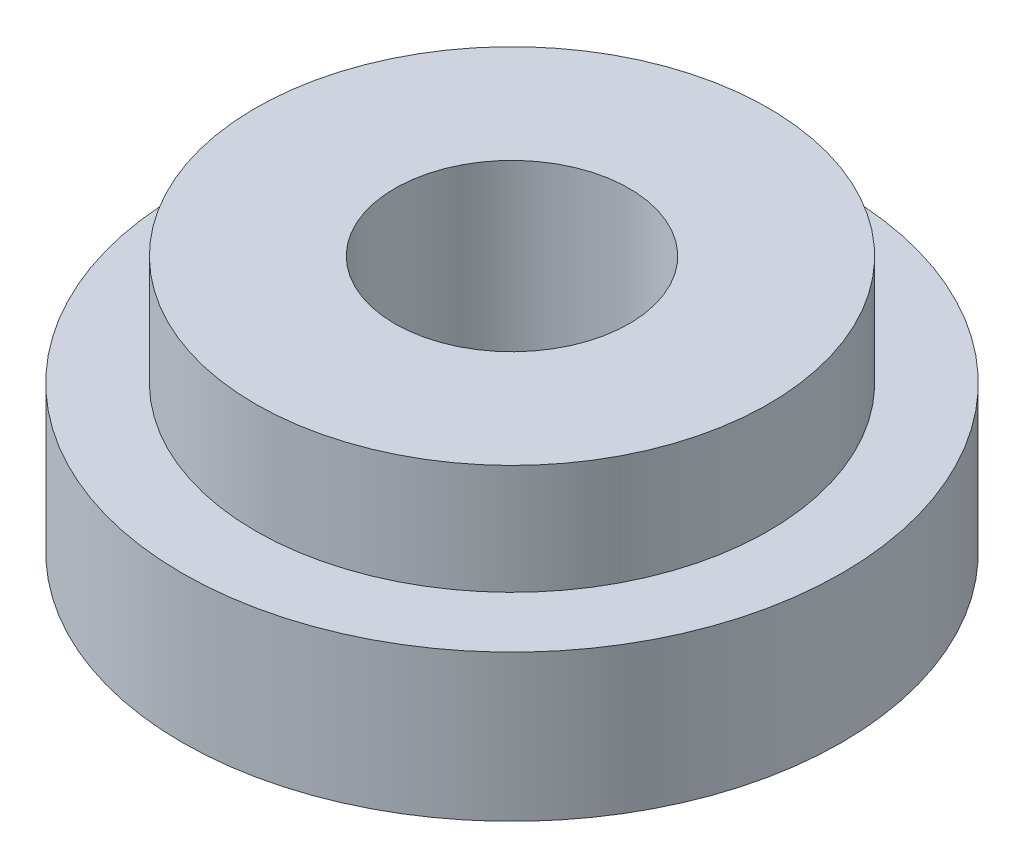
from build123d import *

# Parameters (mm, degrees)
SKETCH1_R           = 4.5
BOSS_EXTRUDE1_DEPTH = 2
SKETCH2_R           = 3.5
BOSS_EXTRUDE2_DEPTH = 1.5
SKETCH3_R           = 1.6
CUT_EXTRUDE1_DEPTH  = 4.5


with BuildPart() as part:
    # Sketch1 → Boss-Extrude1 (new body)
    with BuildSketch(Plane(origin=(0, 0, 0), x_dir=(1, 0, 0), z_dir=(0, 1, 0))):
        Circle(SKETCH1_R)
    extrude(amount=BOSS_EXTRUDE1_DEPTH)

    # Sketch2 → Boss-Extrude2 (add)
    with BuildSketch(Plane(origin=(0, 2, 0), x_dir=(1, 0, 0), z_dir=(0, 1, 0))):
        Circle(SKETCH2_R)
    extrude(amount=BOSS_EXTRUDE2_DEPTH)

    # Sketch3 → Cut-Extrude1 (cut, through all)
    with BuildSketch(Plane(origin=(0, 3.5, 0), x_dir=(1, 0, 0), z_dir=(0, 1, 0))):
        Circle(SKETCH3_R)
    extrude(amount=-CUT_EXTRUDE1_DEPTH, mode=Mode.SUBTRACT)


solid = part.part
